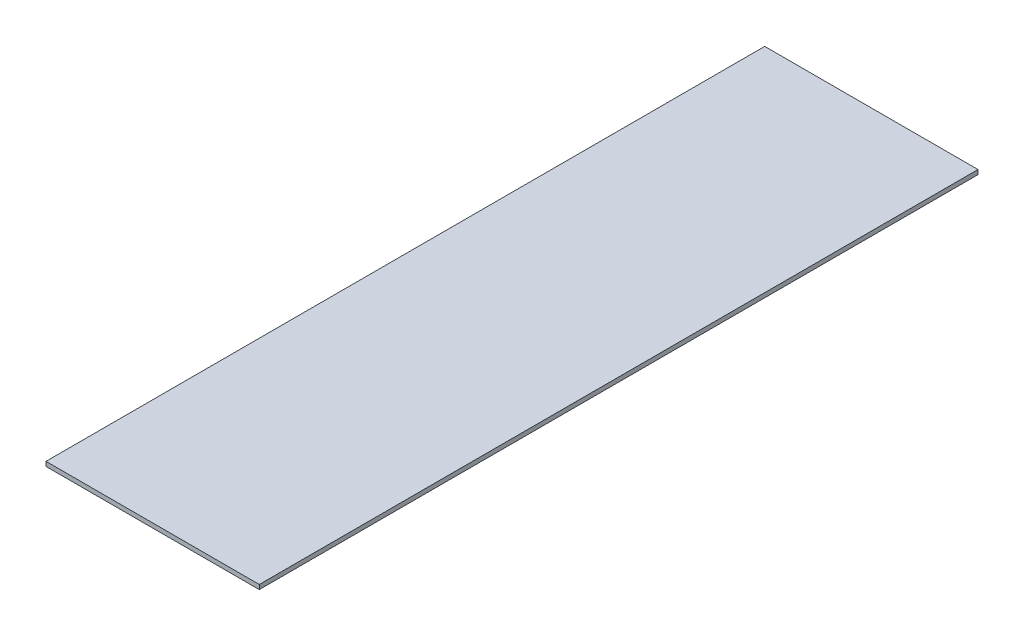
from build123d import *

# Parameters (mm, degrees)
SKETCH1_W           = 96
SKETCH1_H           = 323.5
BOSS_EXTRUDE1_DEPTH = 2


with BuildPart() as part:
    # Sketch1 → Boss-Extrude1 (new body)
    with BuildSketch(Plane(origin=(0, 0, 0), x_dir=(1, 0, 0), z_dir=(0, 1, 0))):
        with Locations((50, 163.75)):
            Rectangle(SKETCH1_W, SKETCH1_H)
    extrude(amount=BOSS_EXTRUDE1_DEPTH)


solid = part.part
